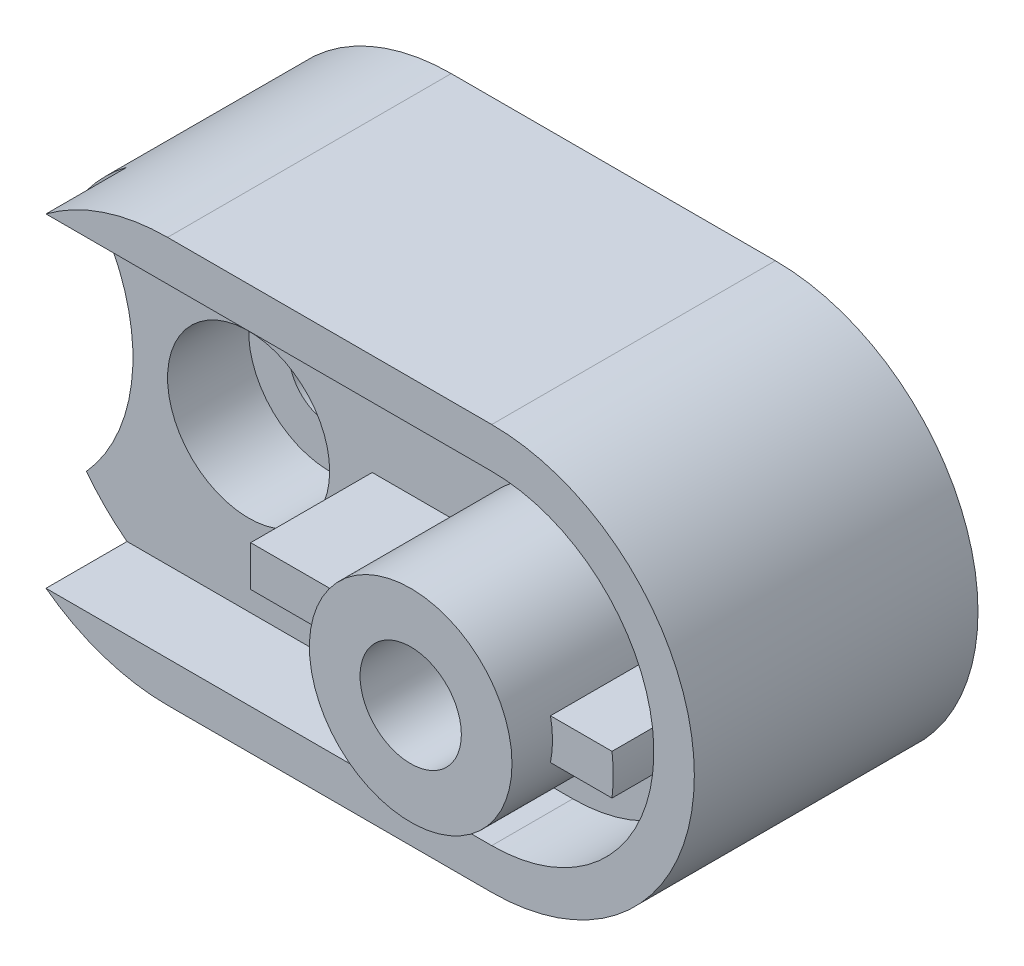
from build123d import *

# Parameters (mm, degrees)
SKETCH1_W                  = 180
SKETCH1_H                  = 100
BOSS_EXTRUDE2_DEPTH        = 70
CUT_EXTRUDE1_DEPTH         = 70
SKETCH3_R                  = 5
CUT_EXTRUDE2_DEPTH         = 70
SKETCH4_R                  = 5
CUT_EXTRUDE3_DEPTH         = 50
SKETCH5_R                  = 10
CUT_EXTRUDE4_DEPTH         = 106
SKETCH6_R                  = 15
CUT_EXTRUDE5_DEPTH         = 40
SKETCH8_R                  = 15
SKETCH8_R_2                = 12.5
BOSS_EXTRUDE3_DEPTH        = 40
SKETCH10_R                 = 12.5
BOSS_EXTRUDE4_DEPTH        = 65
F_25_0MM_DOWEL_HOLE2_D     = 25
F_25_0MM_DOWEL_HOLE2_DEPTH = 20
F_25_0MM_DOWEL_HOLE2_TIP   = 7.510757738
SKETCH12_R                 = 10
SKETCH12_R_2               = 12.5
CUT_EXTRUDE6_DEPTH         = 20
SKETCH13_R                 = 25
SKETCH13_R_2               = 12.5
BOSS_EXTRUDE5_DEPTH        = 40
SKETCH14_R                 = 20
SKETCH14_R_2               = 10
CUT_EXTRUDE7_DEPTH         = 20
BOSS_EXTRUDE10_DEPTH       = 30
BOSS_EXTRUDE13_DEPTH       = 30


with BuildPart() as part:
    # Sketch1 → Boss-Extrude2 (new body)
    with BuildSketch(Plane.XY):
        with Locations((90, 50)):
            Rectangle(SKETCH1_W, SKETCH1_H)
    extrude(amount=BOSS_EXTRUDE2_DEPTH)

    # Sketch2 → Cut-Extrude1 (cut)
    with BuildSketch(Plane.XY.offset(70)):
        with BuildLine():
            Line((50, 100), (0, 100))
            Line((0, 100), (0, 50))
            ThreePointArc((0, 50), (14.644660941, 85.355339059), (50, 100))
        make_face()
        with BuildLine():
            ThreePointArc((50, 0), (14.644660941, 14.644660941), (0, 50))
            Line((0, 50), (0, 0))
            Line((0, 0), (50, 0))
        make_face()
        with BuildLine():
            Line((180, 0), (180, 50))
            ThreePointArc((180, 50), (165.355339059, 14.644660941), (130, 0))
            Line((130, 0), (180, 0))
        make_face()
        with BuildLine():
            Line((180, 100), (130, 100))
            ThreePointArc((130, 100), (165.355339059, 85.355339059), (180, 50))
            Line((180, 50), (180, 100))
        make_face()
    extrude(amount=-CUT_EXTRUDE1_DEPTH, mode=Mode.SUBTRACT)

    # Sketch3 → Cut-Extrude2 (cut)
    with BuildSketch(Plane.XY.offset(70)):
        with Locations((10, 50)):
            Circle(SKETCH3_R)
    extrude(amount=-CUT_EXTRUDE2_DEPTH, mode=Mode.SUBTRACT)

    # Sketch4 → Cut-Extrude3 (cut)
    with BuildSketch(Plane.XY.offset(70)):
        with BuildLine():
            ThreePointArc((10, 20), (21.458980338, 50), (10, 80))
            ThreePointArc((10, 80), (0, 50), (10, 20))
        make_face()
        with Locations((10, 50)):
            Circle(SKETCH4_R, mode=Mode.SUBTRACT)
    extrude(amount=-CUT_EXTRUDE3_DEPTH, mode=Mode.SUBTRACT)

    # Sketch5 → Cut-Extrude4 (cut)
    with BuildSketch(Plane.XY.offset(70)):
        with Locations((50, 50)):
            Circle(SKETCH5_R)
    extrude(amount=-CUT_EXTRUDE4_DEPTH, mode=Mode.SUBTRACT)

    # Sketch6 → Cut-Extrude5 (cut)
    with BuildSketch(Plane.XY.offset(70)):
        with Locations((130, 50)):
            Circle(SKETCH6_R)
    extrude(amount=-CUT_EXTRUDE5_DEPTH, mode=Mode.SUBTRACT)

    # Sketch8 → Boss-Extrude3 (add)
    with BuildSketch(Plane.XY.offset(70)):
        with Locations((130, 50)):
            Circle(SKETCH8_R)
        with Locations((130, 50)):
            Circle(SKETCH8_R_2, mode=Mode.SUBTRACT)
    extrude(amount=-BOSS_EXTRUDE3_DEPTH)

    # Sketch10 → Boss-Extrude4 (add)
    with BuildSketch(Plane.XY.offset(70)):
        with Locations((130, 50)):
            Circle(SKETCH10_R)
    extrude(amount=-BOSS_EXTRUDE4_DEPTH)

    # Ø25.0mm Dowel Hole2
    with Locations(Plane(origin=(130, 50, 70), x_dir=(1, 0, 0), z_dir=(0, 0, 1))):
        with Locations((0, 0)):
            Hole(F_25_0MM_DOWEL_HOLE2_D / 2, depth=F_25_0MM_DOWEL_HOLE2_DEPTH)
            with Locations((0, 0, -(F_25_0MM_DOWEL_HOLE2_DEPTH + F_25_0MM_DOWEL_HOLE2_TIP / 2))):  # 118° drill point
                Cone(0, F_25_0MM_DOWEL_HOLE2_D / 2, F_25_0MM_DOWEL_HOLE2_TIP, mode=Mode.SUBTRACT)

    # Sketch12 → Cut-Extrude6 (cut)
    with BuildSketch(Plane.XY.offset(70)):
        with BuildLine():
            ThreePointArc((130, 10), (170, 50), (130, 90))
            Line((130, 90), (20, 90))
            ThreePointArc((20, 90), (14.644660941, 85.355339059), (10, 80))
            ThreePointArc((10, 80), (21.458980338, 50), (10, 20))
            ThreePointArc((10, 20), (14.644660941, 14.644660941), (20, 10))
            Line((20, 10), (130, 10))
        make_face()
        with Locations((50, 50)):
            Circle(SKETCH12_R, mode=Mode.SUBTRACT)
        with Locations((130, 50)):
            Circle(SKETCH12_R_2, mode=Mode.SUBTRACT)
    extrude(amount=-CUT_EXTRUDE6_DEPTH, mode=Mode.SUBTRACT)

    # Sketch13 → Boss-Extrude5 (add)
    with BuildSketch(Plane.XY.offset(50)):
        with Locations((130, 50)):
            Circle(SKETCH13_R)
        with Locations((130, 50)):
            Circle(SKETCH13_R_2, mode=Mode.SUBTRACT)
    extrude(amount=BOSS_EXTRUDE5_DEPTH)

    # Sketch14 → Cut-Extrude7 (cut)
    with BuildSketch(Plane.XY.offset(50)):
        with Locations((50, 50)):
            Circle(SKETCH14_R)
        with Locations((50, 50)):
            Circle(SKETCH14_R_2, mode=Mode.SUBTRACT)
    extrude(amount=-CUT_EXTRUDE7_DEPTH, mode=Mode.SUBTRACT)

    # Sketch15 → Boss-Extrude10 (add)
    with BuildSketch(Plane.XY.offset(50)):
        with BuildLine():
            Line((105.505102572, 45), (105.505102572, 55))
            ThreePointArc((105.505102572, 55), (105, 50), (105.505102572, 45))
        make_face()
        with BuildLine():
            ThreePointArc((105.505102572, 45), (105, 50), (105.505102572, 55))
            Line((105.505102572, 55), (80.505102572, 55))
            Line((80.505102572, 55), (80.505102572, 45))
            Line((80.505102572, 45), (105.505102572, 45))
        make_face()
    extrude(amount=BOSS_EXTRUDE10_DEPTH)

    # Sketch16 → Boss-Extrude13 (add)
    with BuildSketch(Plane.XY.offset(50)):
        with BuildLine():
            Line((169.686269666, 55), (154.494897428, 55))
            ThreePointArc((154.494897428, 55), (155, 50), (154.494897428, 45))
            Line((154.494897428, 45), (169.686269666, 45))
            ThreePointArc((169.686269666, 45), (169.921490369, 47.495083498), (170, 50))
            ThreePointArc((170, 50), (169.921490369, 52.504916502), (169.686269666, 55))
        make_face()
    extrude(amount=BOSS_EXTRUDE13_DEPTH)


solid = part.part
